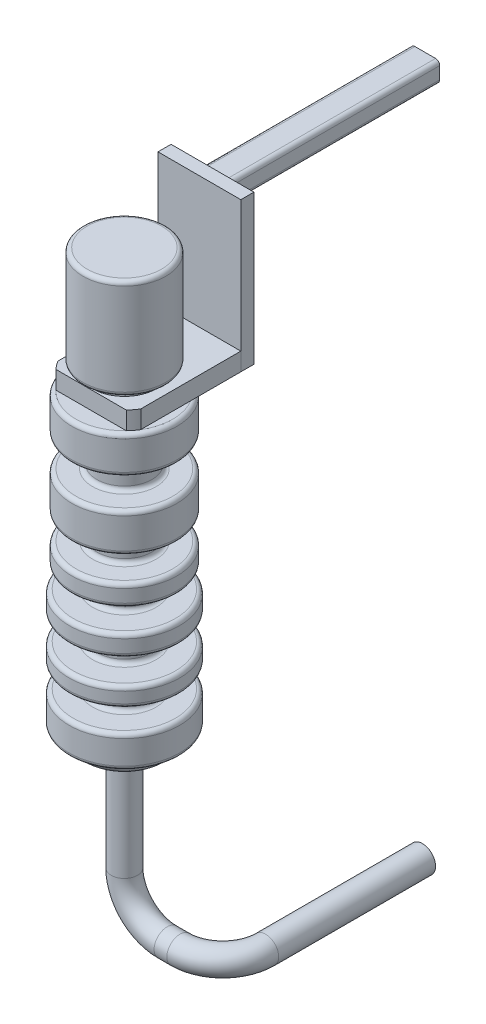
from build123d import *

# Parameters (mm, degrees)
CROQUIS2_R              = 29.733280037
SALIENTE_EXTRUIR1_DEPTH = 10
REDONDEO1_R             = 5
CROQUIS3_R              = 23
SALIENTE_EXTRUIR2_DEPTH = 13
SALIENTE_EXTRUIR3_DEPTH = 108
SALIENTE_EXTRUIR4_DEPTH = 154
BARRER2_PROFILE_R       = 9.5


with BuildPart() as part:
    # Croquis1 → Revolución2 (revolve)
    with BuildSketch(Plane.XY):
        with BuildLine():
            Line((0, 0), (0, 300))
            Line((0, 300), (27, 300))
            ThreePointArc((27, 300), (29.121320344, 299.121320344), (30, 297))
            Line((30, 297), (30, 230.451012724))
            ThreePointArc((30, 230.451012724), (29.121320344, 228.32969238), (27, 227.451012724))
            Line((27, 227.451012724), (23, 227.451012724))
            ThreePointArc((23, 227.451012724), (20.878679656, 226.572333067), (20, 224.451012724))
            Line((20, 224.451012724), (20, 212.89498634))
            ThreePointArc((20, 212.89498634), (20.878679656, 210.773665997), (23, 209.89498634))
            Line((23, 209.89498634), (35.057077789, 209.89498634))
            ThreePointArc((35.057077789, 209.89498634), (37.178398133, 209.016306684), (38.057077789, 206.89498634))
            Line((38.057077789, 206.89498634), (38.057077789, 185.885714981))
            ThreePointArc((38.057077789, 185.885714981), (37.178398133, 183.764394637), (35.057077789, 182.885714981))
            Line((35.057077789, 182.885714981), (23, 182.885714981))
            ThreePointArc((23, 182.885714981), (20.878679656, 182.007035324), (20, 179.885714981))
            Line((20, 179.885714981), (20, 164.553716867))
            ThreePointArc((20, 164.553716867), (20.878679656, 162.432396524), (23, 161.553716867))
            Line((23, 161.553716867), (35.057077789, 161.553716867))
            ThreePointArc((35.057077789, 161.553716867), (37.178398133, 160.675037211), (38.057077789, 158.553716867))
            Line((38.057077789, 158.553716867), (38.057077789, 136.59379475))
            ThreePointArc((38.057077789, 136.59379475), (37.178398133, 134.472474406), (35.057077789, 133.59379475))
            Line((35.057077789, 133.59379475), (23, 133.59379475))
            ThreePointArc((23, 133.59379475), (20.878679656, 132.715115094), (20, 130.59379475))
            Line((20, 130.59379475), (20, 119.037768366))
            ThreePointArc((20, 119.037768366), (20.878679656, 116.916448023), (23, 116.037768366))
            Line((23, 116.037768366), (35.057077789, 116.037768366))
            ThreePointArc((35.057077789, 116.037768366), (37.178398133, 115.15908871), (38.057077789, 113.037768366))
            Line((38.057077789, 113.037768366), (38.057077789, 103.797716867))
            ThreePointArc((38.057077789, 103.797716867), (37.178398133, 101.676396524), (35.057077789, 100.797716867))
            Line((35.057077789, 100.797716867), (23, 100.797716867))
            ThreePointArc((23, 100.797716867), (20.878679656, 99.919037211), (20, 97.797716867))
            Line((20, 97.797716867), (20, 88.857716867))
            ThreePointArc((20, 88.857716867), (20.878679656, 86.736396524), (23, 85.857716867))
            Line((23, 85.857716867), (37, 85.857716867))
            ThreePointArc((37, 85.857716867), (39.121320344, 84.979037211), (40, 82.857716867))
            Line((40, 82.857716867), (40, 73.685167011))
            ThreePointArc((40, 73.685167011), (39.121320344, 71.563846668), (37, 70.685167011))
            Line((37, 70.685167011), (23, 70.685167011))
            ThreePointArc((23, 70.685167011), (20.878679656, 69.806487355), (20, 67.685167011))
            Line((20, 67.685167011), (20, 55.98942738))
            ThreePointArc((20, 55.98942738), (20.878679656, 53.868107037), (23, 52.98942738))
            Line((23, 52.98942738), (37, 52.98942738))
            ThreePointArc((37, 52.98942738), (39.121320344, 52.110747724), (40, 49.98942738))
            Line((40, 49.98942738), (40, 42.085631956))
            ThreePointArc((40, 42.085631956), (39.121320344, 39.964311612), (37, 39.085631956))
            Line((37, 39.085631956), (23, 39.085631956))
            ThreePointArc((23, 39.085631956), (20.878679656, 38.206952299), (20, 36.085631956))
            Line((20, 36.085631956), (20, 26.285864428))
            ThreePointArc((20, 26.285864428), (20.878679656, 24.164544085), (23, 23.285864428))
            Line((23, 23.285864428), (37, 23.285864428))
            ThreePointArc((37, 23.285864428), (39.121320344, 22.407184772), (40, 20.285864428))
            Line((40, 20.285864428), (40, 3))
            ThreePointArc((40, 3), (39.121320344, 0.878679656), (37, 0))
            Line((37, 0), (0, 0))
        make_face()
    revolve(axis=Axis((0, 0, 0), (0, 1, 0)))

    # Croquis2 → Saliente-Extruir1 (add)
    with BuildSketch(Plane.XZ):
        Circle(CROQUIS2_R)
    extrude(amount=SALIENTE_EXTRUIR1_DEPTH)

    # Redondeo1
    redondeo1_edges = [part.edges().sort_by_distance(p)[0] for p in [
        (-29.733280037, -10, 0),
    ]]
    fillet(redondeo1_edges, radius=REDONDEO1_R)

    # Croquis3 → Saliente-Extruir2 (add)
    with BuildSketch(Plane(origin=(0, 209.89498634, 0), x_dir=(1, 0, 0), z_dir=(0, 1, 0))):
        with BuildLine():
            ThreePointArc((-30, 18.138321398), (0, 35.057077789), (30, 18.138321398))
            Line((30, 18.138321398), (30, 54.341897392))
            Line((30, 54.341897392), (-30, 54.341897392))
            Line((-30, 54.341897392), (-30, 18.138321398))
        make_face()
        with BuildLine():
            Line((12.206395984, -24.083270066), (25.475376465, -24.083270066))
            ThreePointArc((25.475376465, -24.083270066), (27.8965043, -21.231668587), (30, -18.138321398))
            Line((30, -18.138321398), (30, 18.138321398))
            ThreePointArc((30, 18.138321398), (0, 35.057077789), (-30, 18.138321398))
            Line((-30, 18.138321398), (-30, -18.138321398))
            ThreePointArc((-30, -18.138321398), (-27.8965043, -21.231668587), (-25.475376465, -24.083270066))
            Line((-25.475376465, -24.083270066), (-12.206395984, -24.083270066))
            ThreePointArc((-12.206395984, -24.083270066), (-14.132008145, 23.006224066), (27, 0))
            ThreePointArc((27, 0), (23.006224066, -14.132008145), (12.206395984, -24.083270066))
        make_face()
        with BuildLine():
            Line((-12.206395984, -24.083270066), (12.206395984, -24.083270066))
            ThreePointArc((12.206395984, -24.083270066), (23.006224066, -14.132008145), (27, 0))
            ThreePointArc((27, 0), (-14.132008145, 23.006224066), (-12.206395984, -24.083270066))
        make_face()
        Circle(CROQUIS3_R, mode=Mode.SUBTRACT)
    extrude(amount=SALIENTE_EXTRUIR2_DEPTH)

    # Barrer2: sweep along a curve in space
    with BuildLine() as barrer2_path:
        Line((0, 0, 0), (0, -89, 0))
        ThreePointArc((0, -89, 0), (9.079689783, -110.920310217, 0), (31, -120, 0))
        Line((31, -120, 0), (40.262942127, -120, 0))
        ThreePointArc((40.262942127, -120, 0), (62.183252344, -120, -9.079689783), (71.262942127, -120, -31))
        Line((71.262942127, -120, -31), (71.262942127, -120, -144.625367206))
    # Barrer2 profile (on start of the path) → Barrer2 (sweep)
    with BuildSketch(Plane(origin=(0, 0, 0), x_dir=(0, 0, -1), z_dir=(0, -1, 0))):
        Circle(BARRER2_PROFILE_R)
    sweep(path=barrer2_path.line)


with BuildPart() as body_2:
    # Croquis4 → Saliente-Extruir3 (new body)
    with BuildSketch(Plane.XZ.offset(-209.89498634)):
        Polygon((30, -54.341897392), (30, -63.812990479), (-29.096122516, -63.812990479), (-30, -63.812990479), (-30, -54.341897392), align=None)
    extrude(amount=-SALIENTE_EXTRUIR3_DEPTH)

    # Croquis5 → Saliente-Extruir4 (add)
    with BuildSketch(Plane(origin=(0, 0, -63.812990479), x_dir=(-1, 0, 0), z_dir=(0, 0, -1))):
        with BuildLine():
            Line((-7.574922315, 298.627020804), (7.315041519, 298.627020804))
            ThreePointArc((7.315041519, 298.627020804), (9.436361863, 299.505700461), (10.315041519, 301.627020804))
            Line((10.315041519, 301.627020804), (10.315041519, 310.535800487))
            ThreePointArc((10.315041519, 310.535800487), (9.436361863, 312.65712083), (7.315041519, 313.535800487))
            Line((7.315041519, 313.535800487), (-7.574922315, 313.535800487))
            ThreePointArc((-7.574922315, 313.535800487), (-9.696242658, 312.65712083), (-10.574922315, 310.535800487))
            Line((-10.574922315, 310.535800487), (-10.574922315, 301.627020804))
            ThreePointArc((-10.574922315, 301.627020804), (-9.696242658, 299.505700461), (-7.574922315, 298.627020804))
        make_face()
    extrude(amount=SALIENTE_EXTRUIR4_DEPTH)


solid = Compound([part.part, body_2.part])
